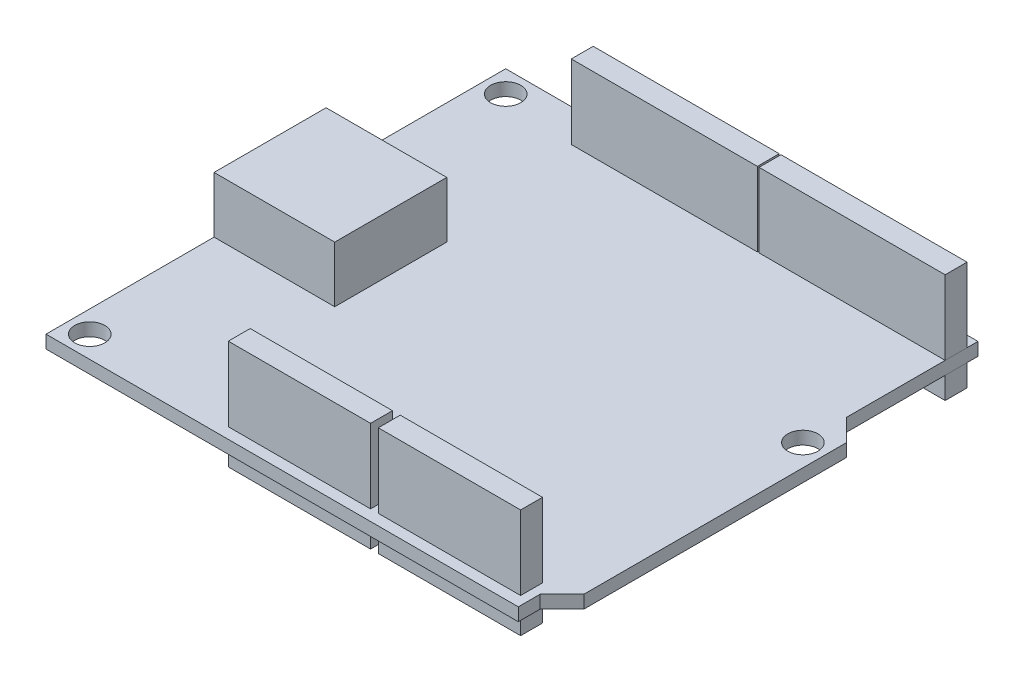
from build123d import *

# Parameters (mm, degrees)
BOSS_EXTRUDE1_DEPTH        = 1.5
SKETCH2_R                  = 1.75
CUT_EXTRUDE1_DEPTH         = 2.5
SKETCH3_W                  = 14
SKETCH3_H                  = 13
BOSS_EXTRUDE2_DEPTH        = 6.5
SKETCH4_W                  = 16.51
SKETCH4_H                  = 2.54
BOSS_EXTRUDE3_DEPTH        = 8.6
BOSS_EXTRUDE3_DEPTH_BACK   = 4.04
BOSS_EXTRUDE3_2_DEPTH      = 8.6
BOSS_EXTRUDE3_2_DEPTH_BACK = 4.04
SKETCH4_W_2                = 21.59
BOSS_EXTRUDE3_3_DEPTH      = 8.6
BOSS_EXTRUDE3_3_DEPTH_BACK = 4.04
BOSS_EXTRUDE3_4_DEPTH      = 8.6
BOSS_EXTRUDE3_4_DEPTH_BACK = 4.04


with BuildPart() as part:
    # Sketch1 → Boss-Extrude1 (new body)
    with BuildSketch(Plane(origin=(0, 0, 0), x_dir=(1, 0, 0), z_dir=(0, 1, 0))):
        Polygon((-27.4, -26.67), (27.4, -26.67), (27.4, -24.13), (29.94, -21.59), (29.94, 8.89), (27.4, 11.43), (27.4, 26.67), (-27.4, 26.67), align=None)
    extrude(amount=BOSS_EXTRUDE1_DEPTH)

    # Sketch2 → Cut-Extrude1 (cut, through all)
    with BuildSketch(Plane(origin=(0, 1.5, 0), x_dir=(1, 0, 0), z_dir=(0, 1, 0))):
        with Locations((-24.86, -24.13)):
            Circle(SKETCH2_R)
        with Locations((-24.86, 24.13)):
            Circle(SKETCH2_R)
        with Locations((27.4, 6.35)):
            Circle(SKETCH2_R)
    extrude(amount=-CUT_EXTRUDE1_DEPTH, mode=Mode.SUBTRACT)


with BuildPart() as body_2:
    # Sketch3 → Boss-Extrude2 (new body)
    with BuildSketch(Plane(origin=(0, 1.5, 0), x_dir=(1, 0, 0), z_dir=(0, 1, 0))):
        with Locations((-20.4, -0.67)):
            Rectangle(SKETCH3_W, SKETCH3_H)
    extrude(amount=BOSS_EXTRUDE2_DEPTH)


with BuildPart() as body_3:
    # Sketch4 → Boss-Extrude3 (new body, two sides)
    with BuildSketch(Plane(origin=(0, 1.5, 0), x_dir=(1, 0, 0), z_dir=(0, 1, 0))) as boss_extrude3_sk:
        with Locations((0.735, -24.13)):
            Rectangle(SKETCH4_W, SKETCH4_H)
    extrude(amount=BOSS_EXTRUDE3_DEPTH)
    extrude(boss_extrude3_sk.sketch, amount=-BOSS_EXTRUDE3_DEPTH_BACK)


with BuildPart() as body_4:
    # Sketch4 → Boss-Extrude3 2 (new body, two sides)
    with BuildSketch(Plane(origin=(0, 1.5, 0), x_dir=(1, 0, 0), z_dir=(0, 1, 0))) as boss_extrude3_2_sk:
        with Locations((18.145, -24.13)):
            Rectangle(SKETCH4_W, SKETCH4_H)
    extrude(amount=BOSS_EXTRUDE3_2_DEPTH)
    extrude(boss_extrude3_2_sk.sketch, amount=-BOSS_EXTRUDE3_2_DEPTH_BACK)


with BuildPart() as body_5:
    # Sketch4 → Boss-Extrude3 3 (new body, two sides)
    with BuildSketch(Plane(origin=(0, 1.5, 0), x_dir=(1, 0, 0), z_dir=(0, 1, 0))) as boss_extrude3_3_sk:
        with Locations((-5.186, 24.13)):
            Rectangle(SKETCH4_W_2, SKETCH4_H)
    extrude(amount=BOSS_EXTRUDE3_3_DEPTH)
    extrude(boss_extrude3_3_sk.sketch, amount=-BOSS_EXTRUDE3_3_DEPTH_BACK)


with BuildPart() as body_6:
    # Sketch4 → Boss-Extrude3 4 (new body, two sides)
    with BuildSketch(Plane(origin=(0, 1.5, 0), x_dir=(1, 0, 0), z_dir=(0, 1, 0))) as boss_extrude3_4_sk:
        with Locations((16.604, 24.13)):
            Rectangle(SKETCH4_W_2, SKETCH4_H)
    extrude(amount=BOSS_EXTRUDE3_4_DEPTH)
    extrude(boss_extrude3_4_sk.sketch, amount=-BOSS_EXTRUDE3_4_DEPTH_BACK)


solid = Compound([part.part, body_2.part, body_3.part, body_4.part, body_5.part, body_6.part])
